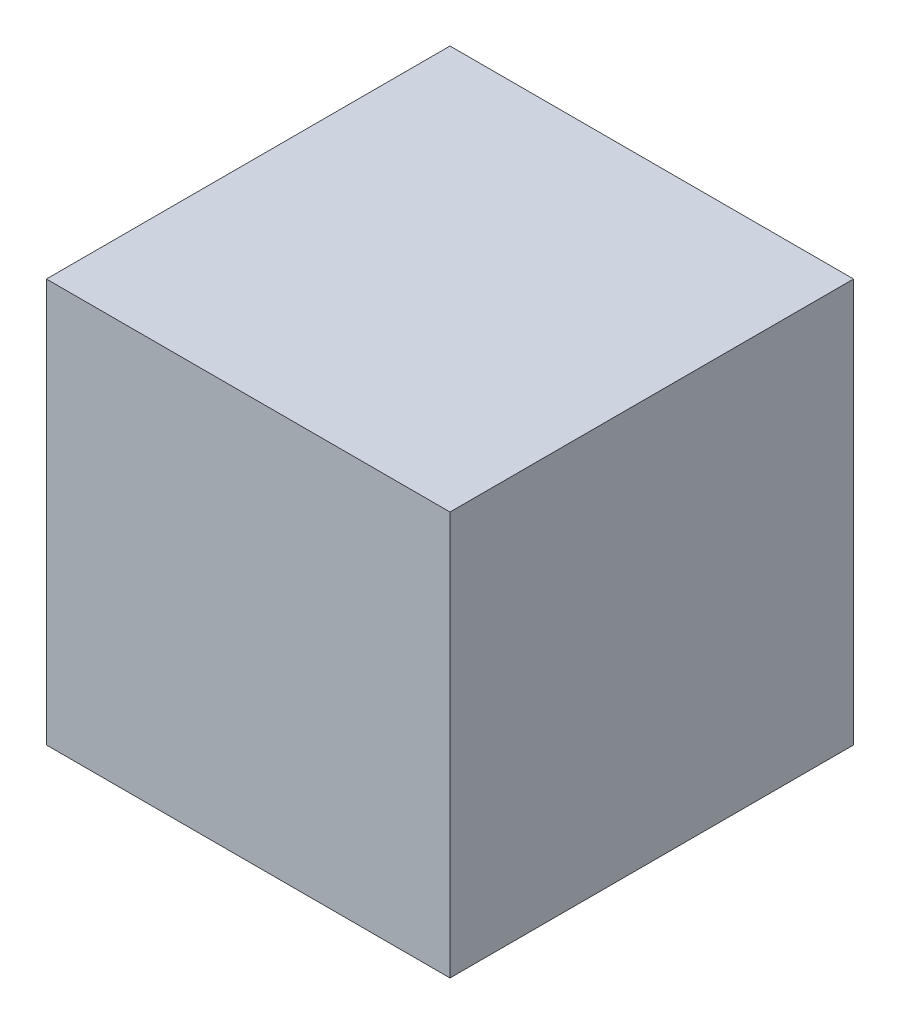
from build123d import *

# Parameters (mm, degrees)
BOSS_EXTRUDE1_DEPTH      = 20
BOSS_EXTRUDE1_DEPTH_BACK = 20
SKETCH1_W                = 40
SKETCH1_H                = 40


with BuildPart() as part:
    # Sketch1 → Boss-Extrude1 (new, two sides: drawn at the far end of the back side and taken through both)
    with BuildSketch(Plane(origin=(0, 0, 0), x_dir=(1, 0, 0), z_dir=(0, 1, 0)).offset(-BOSS_EXTRUDE1_DEPTH_BACK)):
        Rectangle(SKETCH1_W, SKETCH1_H)
    extrude(amount=BOSS_EXTRUDE1_DEPTH + BOSS_EXTRUDE1_DEPTH_BACK)


solid = part.part
